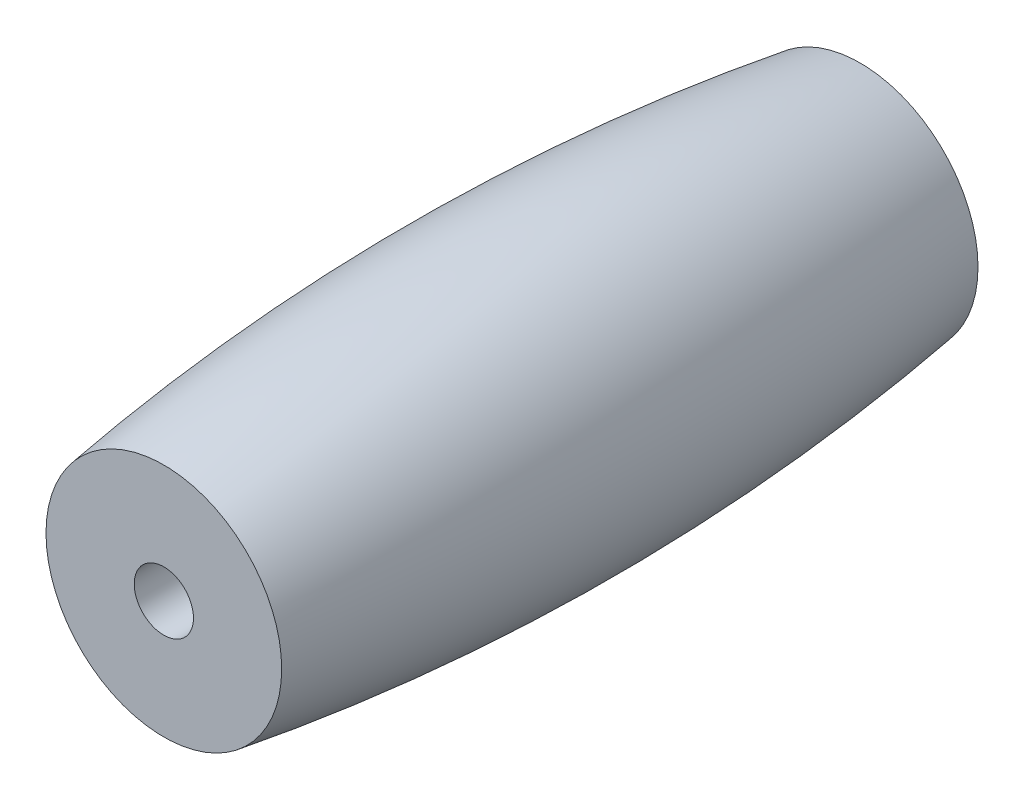
from build123d import *

# Parameters (mm, degrees)
SKETCH3_R          = 2
CUT_EXTRUDE1_DEPTH = 48.0000001


with BuildPart() as part:
    # Sketch2 → Revolve1 (revolve)
    with BuildSketch(Plane(origin=(0, 0, 0), x_dir=(0, 0, -1), z_dir=(1, 0, 0))):
        with BuildLine():
            Line((-23.5, 0), (23.5, 0))
            Line((23.5, 0), (23.5, 7.953950478))
            ThreePointArc((23.5, 7.953950478), (0, 9.725), (-23.5, 7.953950478))
            Line((-23.5, 7.953950478), (-23.5, 0))
        make_face()
    revolve(axis=Axis((0, 0, -25.85), (0, 0, 1)))

    # Sketch3 → Cut-Extrude1 (cut, through all)
    with BuildSketch(Plane.XY.offset(23.5)):
        Circle(SKETCH3_R)
    extrude(amount=-CUT_EXTRUDE1_DEPTH, mode=Mode.SUBTRACT)


solid = part.part
